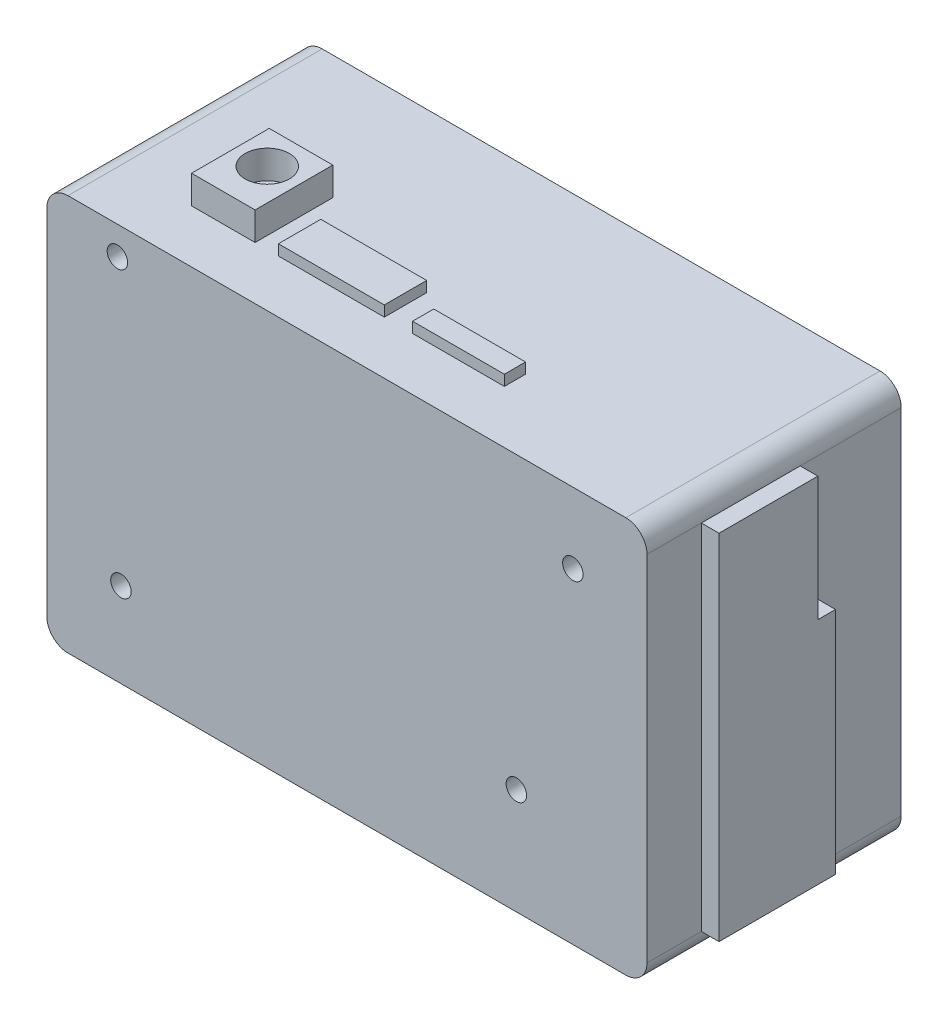
from build123d import *

# Parameters (mm, degrees)
SKETCH1_W           = 85
SKETCH1_H           = 56.1
SKETCH1_R           = 1.45
BOSS_EXTRUDE1_DEPTH = 36
FILLET1_R           = 3
SKETCH3_W           = 2.5
SKETCH3_H           = 32.5
BOSS_EXTRUDE2_DEPTH = 2.5
SKETCH5_W           = 72.026412512
SKETCH5_H           = 46.697666842
BOSS_EXTRUDE3_DEPTH = 2.5
SKETCH6_W           = 9
SKETCH6_H           = 11
SKETCH6_R           = 3.133698946
BOSS_EXTRUDE4_DEPTH = 4
SKETCH8_W           = 15
SKETCH8_H           = 6
SKETCH8_W_2         = 13
SKETCH8_H_2         = 3
BOSS_EXTRUDE5_DEPTH = 1.5


with BuildPart() as part:
    # Sketch1 → Boss-Extrude1 (new body)
    with BuildSketch(Plane.XY):
        Rectangle(SKETCH1_W, SKETCH1_H)
        with Locations((-32.5, 24.05)):
            Circle(SKETCH1_R, mode=Mode.SUBTRACT)
        with Locations((-32, -16.05)):
            Circle(SKETCH1_R, mode=Mode.SUBTRACT)
        with Locations((32, 18.05)):
            Circle(SKETCH1_R, mode=Mode.SUBTRACT)
        with Locations((24, -13.05)):
            Circle(SKETCH1_R, mode=Mode.SUBTRACT)
    extrude(amount=BOSS_EXTRUDE1_DEPTH)

    # Fillet1
    fillet1_edges = [part.edges().sort_by_distance(p)[0] for p in [
        (-42.5, 28.05, 18),
        (42.5, 28.05, 18),
        (42.5, -28.05, 18),
        (-42.5, -28.05, 18),
    ]]
    fillet(fillet1_edges, radius=FILLET1_R)

    # Sketch3 → Boss-Extrude2 (add)
    with BuildSketch(Plane(origin=(42.5, 0, 0), x_dir=(0, 0, -1), z_dir=(1, 0, 0))):
        Polygon((-14.3, 7.45), (-14.3, 25.05), (-28.3, 25.05), (-28.3, -25.05), (-14.3, -25.05), align=None)
        with Locations((-13.05, -8.8)):
            Rectangle(SKETCH3_W, SKETCH3_H)
    extrude(amount=BOSS_EXTRUDE2_DEPTH)

    # Sketch5 → Boss-Extrude3 (add)
    with BuildSketch(Plane(origin=(0, 0, 0), x_dir=(-1, 0, 0), z_dir=(0, 0, -1))):
        with Locations((0.359054428, 3.107329256)):
            Rectangle(SKETCH5_W, SKETCH5_H)
    extrude(amount=-BOSS_EXTRUDE3_DEPTH)

    # Sketch6 → Boss-Extrude4 (add)
    with BuildSketch(Plane(origin=(0, 28.05, 0), x_dir=(1, 0, 0), z_dir=(0, 1, 0))):
        with Locations((-25, -23)):
            Rectangle(SKETCH6_W, SKETCH6_H)
        with Locations((-25, -22.280322914)):
            Circle(SKETCH6_R, mode=Mode.SUBTRACT)
    extrude(amount=BOSS_EXTRUDE4_DEPTH)

    # Sketch8 → Boss-Extrude5 (add)
    with BuildSketch(Plane(origin=(0, 28.05, 0), x_dir=(1, 0, 0), z_dir=(0, 1, 0))):
        with Locations((-9.7, -25.5)):
            Rectangle(SKETCH8_W, SKETCH8_H)
        with Locations((8.3, -27)):
            Rectangle(SKETCH8_W_2, SKETCH8_H_2)
    extrude(amount=BOSS_EXTRUDE5_DEPTH)


solid = part.part
